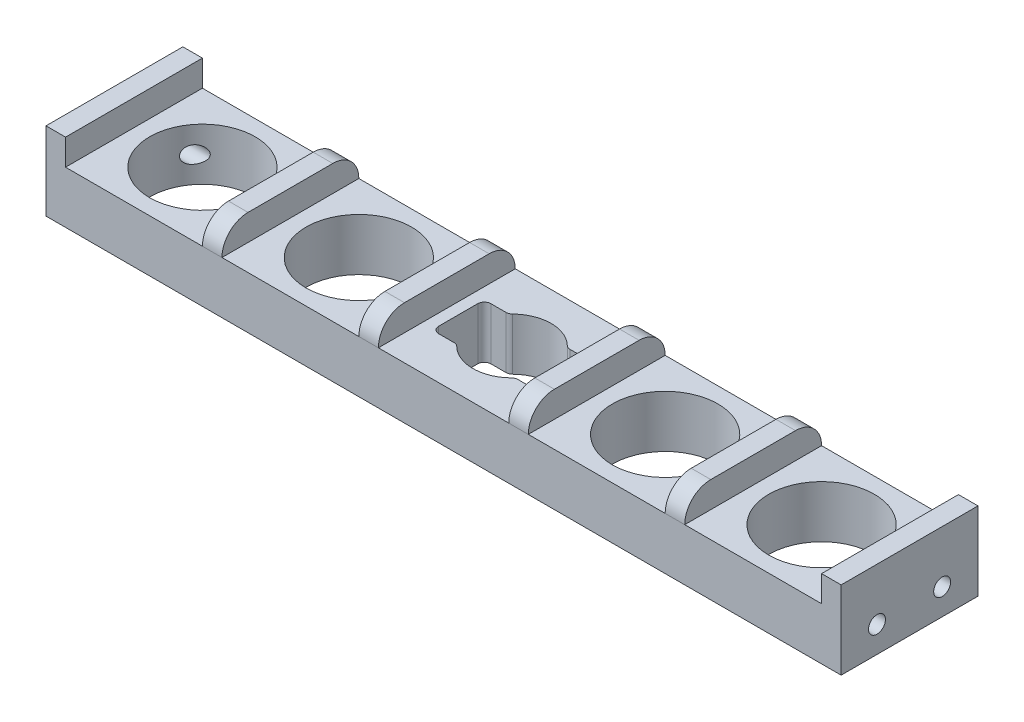
from build123d import *

# Parameters (mm, degrees)
SKETCH1_W           = 122
SKETCH1_H           = 21
SKETCH1_R           = 8.1
BOSS_EXTRUDE1_DEPTH = 8
CUT_EXTRUDE1_DEPTH  = 122
FILLET2_R           = 1
SKETCH6_W           = 3
SKETCH6_H           = 21
BOSS_EXTRUDE4_DEPTH = 4
FILLET3_R           = 4
SKETCH7_R           = 1.3
CUT_EXTRUDE2_DEPTH  = 10


with BuildPart() as part:
    # Sketch1 → Boss-Extrude1 (new body)
    with BuildSketch(Plane(origin=(0, 0, 0), x_dir=(1, 0, 0), z_dir=(0, 1, 0))):
        Rectangle(SKETCH1_W, SKETCH1_H)
        with Locations((-47.5, 0)):
            Circle(SKETCH1_R, mode=Mode.SUBTRACT)
        with Locations((-23.5, 0)):
            Circle(SKETCH1_R, mode=Mode.SUBTRACT)
        with Locations((23.5, 0)):
            Circle(SKETCH1_R, mode=Mode.SUBTRACT)
        with Locations((47.5, 0)):
            Circle(SKETCH1_R, mode=Mode.SUBTRACT)
    extrude(amount=BOSS_EXTRUDE1_DEPTH)

    # Sketch4 → Cut-Extrude1 (cut)
    with BuildSketch(Plane(origin=(0, 8, 0), x_dir=(1, 0, 0), z_dir=(0, 1, 0))):
        with BuildLine():
            Line((8.25, 4), (4.472135955, 4))
            ThreePointArc((4.472135955, 4), (5.605034154, 2.140932539), (6, 0))
            ThreePointArc((6, 0), (5.605034154, -2.140932539), (4.472135955, -4))
            Line((4.472135955, -4), (8.25, -4))
            Line((8.25, -4), (8.25, 4))
        make_face()
        with BuildLine():
            Line((4.472135955, 4), (-4.472135955, 4))
            ThreePointArc((-4.472135955, 4), (-6, 0), (-4.472135955, -4))
            Line((-4.472135955, -4), (4.472135955, -4))
            ThreePointArc((4.472135955, -4), (5.605034154, -2.140932539), (6, 0))
            ThreePointArc((6, 0), (5.605034154, 2.140932539), (4.472135955, 4))
        make_face()
        with BuildLine():
            ThreePointArc((4.472135955, 4), (0, 6), (-4.472135955, 4))
            Line((-4.472135955, 4), (4.472135955, 4))
        make_face()
        with BuildLine():
            Line((4.472135955, -4), (-4.472135955, -4))
            ThreePointArc((-4.472135955, -4), (0, -6), (4.472135955, -4))
        make_face()
        with BuildLine():
            Line((-4.472135955, 4), (-8.25, 4))
            Line((-8.25, 4), (-8.25, -4))
            Line((-8.25, -4), (-4.472135955, -4))
            ThreePointArc((-4.472135955, -4), (-6, 0), (-4.472135955, 4))
        make_face()
    extrude(amount=-CUT_EXTRUDE1_DEPTH, mode=Mode.SUBTRACT)

    # Fillet2
    fillet2_edges = [part.edges().sort_by_distance(p)[0] for p in [
        (4.472135955, 4, -4),
        (8.25, 4, -4),
        (8.25, 4, 4),
        (4.472135955, 4, 4),
        (-4.472135955, 4, 4),
        (-8.25, 4, 4),
        (-8.25, 4, -4),
        (-4.472135955, 4, -4),
    ]]
    fillet(fillet2_edges, radius=FILLET2_R)

    # Sketch6 → Boss-Extrude4 (add)
    with BuildSketch(Plane(origin=(0, 8, 0), x_dir=(1, 0, 0), z_dir=(0, 1, 0))):
        with Locations((-59.5, 0)):
            Rectangle(SKETCH6_W, SKETCH6_H)
        with Locations((-35.5, 0)):
            Rectangle(SKETCH6_W, SKETCH6_H)
        with Locations((35.5, 0)):
            Rectangle(SKETCH6_W, SKETCH6_H)
        with Locations((59.5, 0)):
            Rectangle(SKETCH6_W, SKETCH6_H)
        with Locations((-11.5, 0)):
            Rectangle(SKETCH6_W, SKETCH6_H)
        with Locations((11.5, 0)):
            Rectangle(SKETCH6_W, SKETCH6_H)
    extrude(amount=BOSS_EXTRUDE4_DEPTH)

    # Fillet3
    fillet3_edges = [part.edges().sort_by_distance(p)[0] for p in [
        (35.5, 12, 10.5),
        (11.5, 12, 10.5),
        (-11.5, 12, 10.5),
        (-35.5, 12, 10.5),
        (35.5, 12, -10.5),
        (11.5, 12, -10.5),
        (-11.5, 12, -10.5),
        (-35.5, 12, -10.5),
    ]]
    fillet(fillet3_edges, radius=FILLET3_R)

    # Sketch7 → Cut-Extrude2 (cut)
    with BuildSketch(Plane(origin=(61, 0, 0), x_dir=(0, 0, -1), z_dir=(1, 0, 0))):
        with Locations((-5, 4)):
            Circle(SKETCH7_R)
        with Locations((5, 4)):
            Circle(SKETCH7_R)
    cut_extrude2 = extrude(amount=-CUT_EXTRUDE2_DEPTH, mode=Mode.SUBTRACT)

    # Mirror1: Cut-Extrude2 across plane
    add(cut_extrude2.mirror(Plane(origin=(0, 0, 0), x_dir=(0, 0, 1), z_dir=(1, 0, 0))), mode=Mode.SUBTRACT)


solid = part.part
